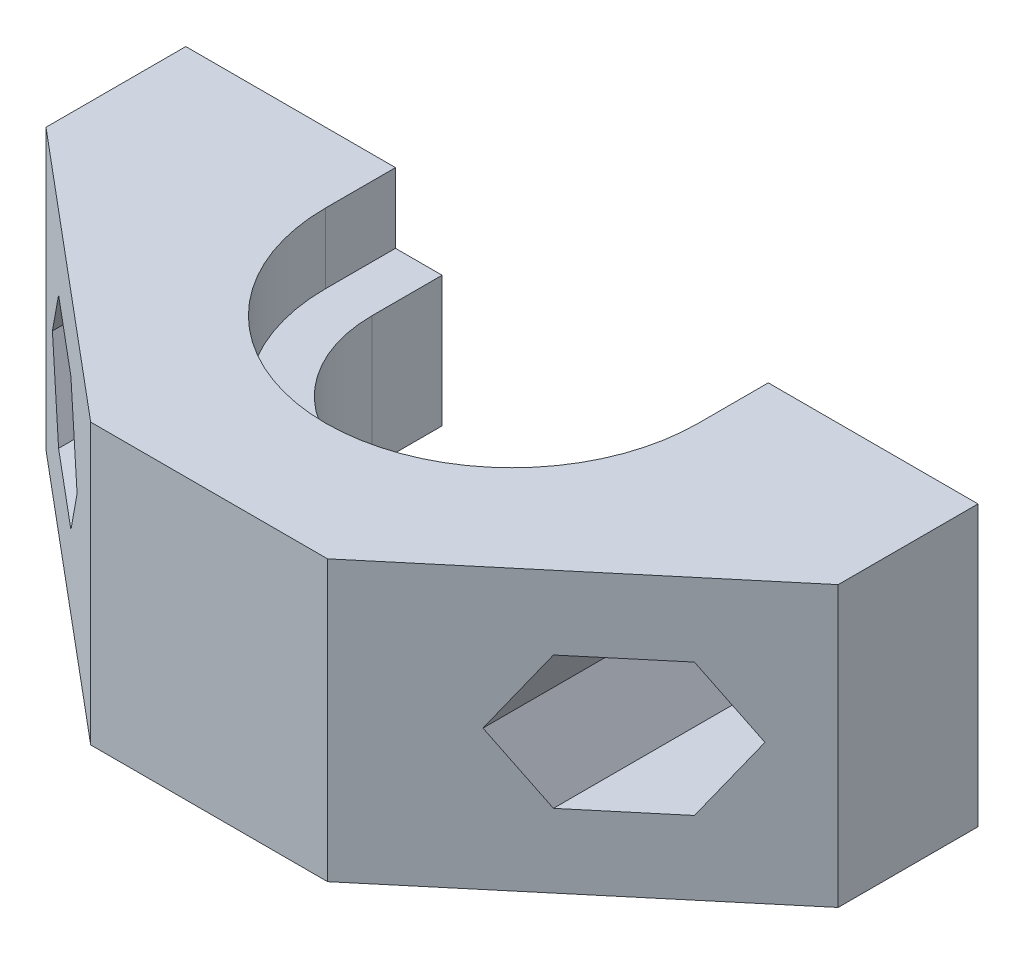
from build123d import *

# Parameters (mm, degrees)
EXTRUDE_1_DEPTH          = 3.4
EXTRUDE_2_DEPTH          = 5.6
EXTRUDE_3_DEPTH          = 3
SKETCH_5_R               = 1.65
CUT_EXTRUDE_2_DEPTH      = 4
CUT_EXTRUDE_2_DEPTH_BACK = 14
CUT_EXTRUDE_1_REACH      = 15


with BuildPart() as part:
    # 草图1 → 凸台-拉伸1 (new body)
    with BuildSketch(Plane(origin=(0, 0, 0), x_dir=(1, 0, 0), z_dir=(0, 1, 0))):
        with BuildLine():
            Line((-17, -3), (-5.082464074, -13))
            Line((-5.082464074, -13), (5.082464074, -13))
            Line((5.082464074, -13), (17, -3))
            Line((17, -3), (17, 0))
            Line((17, 0), (17, 3))
            Line((17, 3), (7.984491068, 3))
            Line((7.984491068, 3), (7.984491068, 0))
            Line((7.984491068, 0), (8, 0))
            ThreePointArc((8, 0), (0, -8), (-8, 0))
            Line((-8, 0), (-8, 3))
            Line((-8, 3), (-17, 3))
            Line((-17, 3), (-17, -3))
        make_face()
    extrude(amount=EXTRUDE_1_DEPTH)

    # 草图2 → 凸台-拉伸2 (add)
    with BuildSketch(Plane(origin=(0, 3.4, 0), x_dir=(1, 0, 0), z_dir=(0, 1, 0))):
        with BuildLine():
            Line((-17, -3), (-5.082464074, -13))
            Line((-5.082464074, -13), (5.082464074, -13))
            Line((5.082464074, -13), (17, -3))
            Line((17, -3), (17, 3))
            Line((17, 3), (6, 3))
            Line((6, 3), (6, 0))
            ThreePointArc((6, 0), (0, -6), (-6, 0))
            Line((-6, 0), (-6, 3))
            Line((-6, 3), (-17, 3))
            Line((-17, 3), (-17, -3))
        make_face()
    extrude(amount=EXTRUDE_2_DEPTH)

    # 草图3 → 凸台-拉伸3 (add)
    with BuildSketch(Plane(origin=(0, 9, 0), x_dir=(1, 0, 0), z_dir=(0, 1, 0))):
        with BuildLine():
            Line((-17, -3), (-5.082464074, -13))
            Line((-5.082464074, -13), (5.082464074, -13))
            Line((5.082464074, -13), (17, -3))
            Line((17, -3), (17, 3))
            Line((17, 3), (8, 3))
            Line((8, 3), (8, 0))
            ThreePointArc((8, 0), (0, -8), (-8, 0))
            Line((-8, 0), (-8, 3))
            Line((-8, 3), (-17, 3))
            Line((-17, 3), (-17, -3))
        make_face()
    extrude(amount=EXTRUDE_3_DEPTH)

    # 草图5 → 切除-拉伸2 (cut, two sides)
    with BuildSketch(Plane(origin=(0, 0, 0), x_dir=(-1, 0, 0), z_dir=(0, 0, -1))) as cut_extrude_2_sk:
        with Locations((12, 6)):
            Circle(SKETCH_5_R)
        with Locations((-12, 6)):
            Circle(SKETCH_5_R)
    extrude(amount=CUT_EXTRUDE_2_DEPTH, mode=Mode.SUBTRACT)
    extrude(cut_extrude_2_sk.sketch, amount=-CUT_EXTRUDE_2_DEPTH_BACK, mode=Mode.SUBTRACT)

    # 草图4 → 切除-拉伸1 (cut, up to next)
    with BuildSketch(Plane(origin=(0, 0, 0), x_dir=(-1, 0, 0), z_dir=(0, 0, -1)), mode=Mode.PRIVATE) as cut_extrude_1_sk1:
        Polygon((10.354551733, 3.15), (13.645448267, 3.15), (15.290896534, 6), (13.645448267, 8.85), (10.354551733, 8.85), (8.709103466, 6), align=None)
    cut_extrude_1_tool1 = extrude(cut_extrude_1_sk1.sketch, amount=-CUT_EXTRUDE_1_REACH, mode=Mode.PRIVATE) & part.part
    add(cut_extrude_1_tool1.solids().sort_by_distance((-12, 6, 0))[0], mode=Mode.SUBTRACT)
    # 草图4 → 切除-拉伸1 (cut, up to next)
    with BuildSketch(Plane(origin=(0, 0, 0), x_dir=(-1, 0, 0), z_dir=(0, 0, -1)), mode=Mode.PRIVATE) as cut_extrude_1_sk2:
        Polygon((-13.645448267, 3.15), (-10.354551733, 3.15), (-8.709103466, 6), (-10.354551733, 8.85), (-13.645448267, 8.85), (-15.290896534, 6), align=None)
    cut_extrude_1_tool2 = extrude(cut_extrude_1_sk2.sketch, amount=-CUT_EXTRUDE_1_REACH, mode=Mode.PRIVATE) & part.part
    add(cut_extrude_1_tool2.solids().sort_by_distance((12, 6, 0))[0], mode=Mode.SUBTRACT)


solid = part.part
